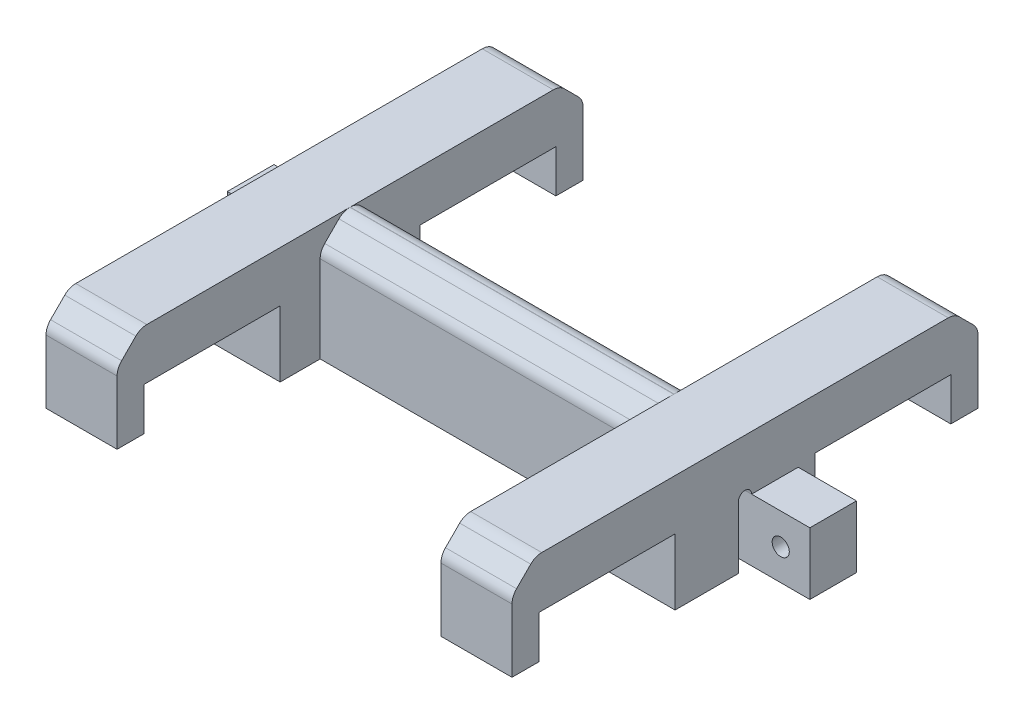
from build123d import *

# Parameters (mm, degrees)
SKETCH1_W                = 60
SKETCH1_H                = 15
BOSS_EXTRUDE1_DEPTH      = 30
SKETCH2_W                = 60
SKETCH2_H                = 1.7
CUT_EXTRUDE1_DEPTH       = 8
SKETCH3_W                = 60
SKETCH3_H                = 1.8
CUT_EXTRUDE2_DEPTH       = 8.5
SKETCH4_W                = 60
SKETCH4_H                = 24
CUT_EXTRUDE3_DEPTH       = 3
SKETCH5_W                = 41.7
SKETCH5_H                = 24
CUT_EXTRUDE4_DEPTH       = 27
SKETCH6_W                = 60
SKETCH6_H                = 9.5
CUT_EXTRUDE5_DEPTH       = 8.5
SKETCH7_W                = 60
SKETCH7_H                = 17.5
CUT_EXTRUDE6_DEPTH       = 25
SKETCH9_W                = 9.15
SKETCH9_H                = 3
BOSS_EXTRUDE2_DEPTH      = 5
SKETCH10_W               = 41.7
SKETCH10_H               = 5.15
CUT_EXTRUDE7_DEPTH       = 23
CHAMFER1_SIZE            = 3
FILLET1_R                = 2
SKETCH11_W               = 7.5
SKETCH11_H               = 8
BOSS_EXTRUDE3_DEPTH      = 6
SKETCH12_R               = 1.9
CUT_EXTRUDE8_DEPTH       = 4
M2_CLEARANCE_HOLE1_D     = 2.2
M2_CLEARANCE_HOLE1_DEPTH = 10
SKETCH16_R               = 0.85
CUT_EXTRUDE9_DEPTH       = 81


with BuildPart() as part:
    # Sketch1 → Boss-Extrude1 (new body, symmetric)
    with BuildSketch(Plane.XY):
        Rectangle(SKETCH1_W, SKETCH1_H)
    extrude(amount=BOSS_EXTRUDE1_DEPTH, both=True)

    # Sketch2 → Cut-Extrude1 (cut)
    with BuildSketch(Plane.XZ.offset(7.5)):
        Rectangle(SKETCH2_W, SKETCH2_H)
    extrude(amount=-CUT_EXTRUDE1_DEPTH, mode=Mode.SUBTRACT)

    # Sketch3 → Cut-Extrude2 (cut)
    with BuildSketch(Plane.XZ.offset(7.5)):
        with Locations((0, -12.1)):
            Rectangle(SKETCH3_W, SKETCH3_H)
        with Locations((0, -23.4)):
            Rectangle(SKETCH3_W, SKETCH3_H)
    cut_extrude2 = extrude(amount=-CUT_EXTRUDE2_DEPTH, mode=Mode.SUBTRACT)

    # Sketch4 → Cut-Extrude3 (cut)
    with BuildSketch(Plane.XZ.offset(7.5)):
        with Locations((0, 18)):
            Rectangle(SKETCH4_W, SKETCH4_H)
    cut_extrude3 = extrude(amount=-CUT_EXTRUDE3_DEPTH, mode=Mode.SUBTRACT)

    # Sketch5 → Cut-Extrude4 (cut)
    with BuildSketch(Plane.XZ.offset(7.5)):
        with Locations((0, 18)):
            Rectangle(SKETCH5_W, SKETCH5_H)
    cut_extrude4 = extrude(amount=-CUT_EXTRUDE4_DEPTH, mode=Mode.SUBTRACT)

    # Sketch6 → Cut-Extrude5 (cut)
    with BuildSketch(Plane.XZ.offset(7.5)):
        with Locations((0, -17.75)):
            Rectangle(SKETCH6_W, SKETCH6_H)
    cut_extrude5 = extrude(amount=-CUT_EXTRUDE5_DEPTH, mode=Mode.SUBTRACT)

    # Sketch7 → Cut-Extrude6 (cut)
    with BuildSketch(Plane.XZ.offset(-1)):
        with Locations((0, -17.75)):
            Rectangle(SKETCH7_W, SKETCH7_H)
    cut_extrude6 = extrude(amount=CUT_EXTRUDE6_DEPTH, mode=Mode.SUBTRACT)

    # Mirror1: Cut-Extrude2, Cut-Extrude3, Cut-Extrude4, Cut-Extrude5, Cut-Extrude6 across plane
    add(cut_extrude2.mirror(Plane.XY), mode=Mode.SUBTRACT)
    add(cut_extrude3.mirror(Plane.XY), mode=Mode.SUBTRACT)
    add(cut_extrude4.mirror(Plane.XY), mode=Mode.SUBTRACT)
    add(cut_extrude5.mirror(Plane.XY), mode=Mode.SUBTRACT)
    add(cut_extrude6.mirror(Plane.XY), mode=Mode.SUBTRACT)

    # Sketch9 → Boss-Extrude2 (add)
    with BuildSketch(Plane.XZ.offset(7.5)):
        with Locations((-25.425, 7.5)):
            Rectangle(SKETCH9_W, SKETCH9_H)
        with Locations((-25.425, -7.5)):
            Rectangle(SKETCH9_W, SKETCH9_H)
        with Locations((25.425, -7.5)):
            Rectangle(SKETCH9_W, SKETCH9_H)
        with Locations((25.425, 7.5)):
            Rectangle(SKETCH9_W, SKETCH9_H)
    extrude(amount=-BOSS_EXTRUDE2_DEPTH)

    # Sketch10 → Cut-Extrude7 (cut)
    with BuildSketch(Plane.XZ.offset(7.5)):
        with Locations((0, 6.425)):
            Rectangle(SKETCH10_W, SKETCH10_H)
    cut_extrude7 = extrude(amount=-CUT_EXTRUDE7_DEPTH, mode=Mode.SUBTRACT)

    # Mirror2: Cut-Extrude7 across plane
    add(cut_extrude7.mirror(Plane.XY), mode=Mode.SUBTRACT)

    # Chamfer1
    chamfer1_edges = [part.edges().sort_by_distance(p)[0] for p in [
        (25.425, 7.5, 30),
        (-25.425, 7.5, -30),
        (0, 7.5, 3.85),
        (0, 7.5, -3.85),
        (25.425, 7.5, -30),
        (-25.425, 7.5, 30),
    ]]
    chamfer(chamfer1_edges, length=CHAMFER1_SIZE)

    # Fillet1
    fillet1_edges = [part.edges().sort_by_distance(p)[0] for p in [
        (0, 4.5, -3.85),
        (-25.425, 7.5, 27),
        (25.425, 7.5, 27),
        (25.425, 7.5, -27),
        (-25.425, 7.5, -27),
        (0, 7.5, 0.85),
        (0, 7.5, -0.85),
        (0, 4.5, 3.85),
        (-25.425, 4.5, -30),
        (25.425, 4.5, -30),
        (25.425, 4.5, 30),
        (-25.425, 4.5, 30),
    ]]
    fillet(fillet1_edges, radius=FILLET1_R)

    # Sketch11 → Boss-Extrude3 (add)
    with BuildSketch(Plane.XY.offset(-0.85)):
        with Locations((-33.75, -3.5)):
            Rectangle(SKETCH11_W, SKETCH11_H)
        with Locations((33.75, -3.5)):
            Rectangle(SKETCH11_W, SKETCH11_H)
    extrude(amount=-BOSS_EXTRUDE3_DEPTH)

    # Sketch12 → Cut-Extrude8 (cut)
    with BuildSketch(Plane(origin=(0, 0, -6.85), x_dir=(-1, 0, 0), z_dir=(0, 0, -1))):
        with Locations((33.75, -3.5)):
            Circle(SKETCH12_R)
    cut_extrude8 = extrude(amount=-CUT_EXTRUDE8_DEPTH, mode=Mode.SUBTRACT)

    # M2 Clearance Hole1
    with Locations(Plane(origin=(0, 0, -6.85), x_dir=(-1, 0, 0), z_dir=(0, 0, -1))):
        with Locations((33.75, -3.5)):
            m2_clearance_hole1 = Hole(M2_CLEARANCE_HOLE1_D / 2, depth=M2_CLEARANCE_HOLE1_DEPTH)

    # Mirror3: Cut-Extrude8, M2 Clearance Hole1 across plane
    add(cut_extrude8.mirror(Plane(origin=(0, 0, 0), x_dir=(0, 0, 1), z_dir=(1, 0, 0))), mode=Mode.SUBTRACT)
    add(m2_clearance_hole1.mirror(Plane(origin=(0, 0, 0), x_dir=(0, 0, 1), z_dir=(1, 0, 0))), mode=Mode.SUBTRACT)

    # Sketch16 → Cut-Extrude9 (cut)
    with BuildSketch(Plane.ZY.offset(37.5)):
        with Locations((0, 0.5)):
            Circle(SKETCH16_R)
    extrude(amount=-CUT_EXTRUDE9_DEPTH, mode=Mode.SUBTRACT)


solid = part.part
